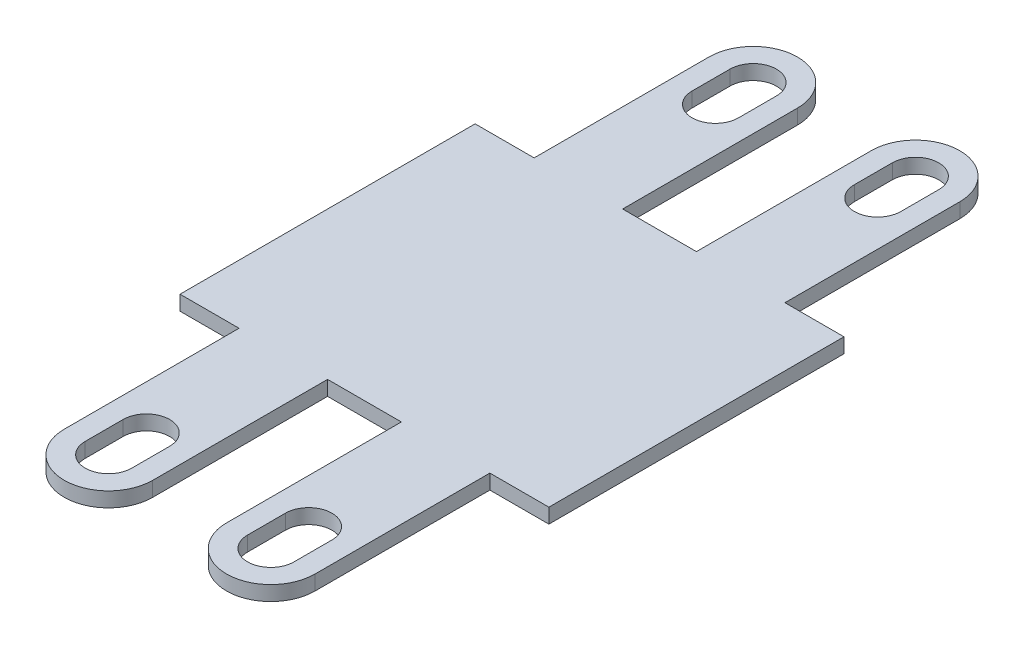
from build123d import *

# Parameters (mm, degrees)
BOSS_EXTRUDE1_DEPTH = 2


with BuildPart() as part:
    # Sketch1 → Boss-Extrude1 (new body)
    with BuildSketch(Plane(origin=(0, 0, 0), x_dir=(1, 0, 0), z_dir=(0, 1, 0))):
        with BuildLine():
            Line((-23.335340856, 23.970044555), (-15.335340856, 23.970044555))
            Line((-15.335340856, 23.970044555), (-15.335340856, 47.670044555))
            ThreePointArc((-15.335340856, 47.670044555), (-9.335340856, 53.670044555), (-3.335340856, 47.670044555))
            Line((-3.335340856, 47.670044555), (-3.335340856, 23.970044555))
            Line((-3.335340856, 23.970044555), (6.664659144, 23.970044555))
            Line((6.664659144, 23.970044555), (6.664659144, 47.670044555))
            ThreePointArc((6.664659144, 47.670044555), (12.664659144, 53.670044555), (18.664659144, 47.670044555))
            Line((18.664659144, 47.670044555), (18.664659144, 23.970044555))
            Line((18.664659144, 23.970044555), (26.664659144, 23.970044555))
            Line((26.664659144, 23.970044555), (26.664659144, -16.029955445))
            Line((26.664659144, -16.029955445), (18.664659144, -16.029955445))
            Line((18.664659144, -16.029955445), (18.664659144, -39.729955445))
            ThreePointArc((18.664659144, -39.729955445), (12.664659144, -45.729955445), (6.664659144, -39.729955445))
            Line((6.664659144, -39.729955445), (6.664659144, -16.029955445))
            Line((6.664659144, -16.029955445), (-3.335340856, -16.029955445))
            Line((-3.335340856, -16.029955445), (-3.335340856, -39.729955445))
            ThreePointArc((-3.335340856, -39.729955445), (-9.335340856, -45.729955445), (-15.335340856, -39.729955445))
            Line((-15.335340856, -39.729955445), (-15.335340856, -16.029955445))
            Line((-15.335340856, -16.029955445), (-23.335340856, -16.029955445))
            Line((-23.335340856, -16.029955445), (-23.335340856, 23.970044555))
        make_face()
        with BuildLine():
            Line((9.514659144, 47.670044555), (9.514659144, 42.529492266))
            ThreePointArc((9.514659144, 42.529492266), (12.664659144, 39.379492266), (15.814659144, 42.529492266))
            Line((15.814659144, 42.529492266), (15.814659144, 47.670044555))
            ThreePointArc((15.814659144, 47.670044555), (12.664659144, 50.820044555), (9.514659144, 47.670044555))
        make_face(mode=Mode.SUBTRACT)
        with BuildLine():
            Line((-6.185340856, 47.670044555), (-6.185340856, 42.529492266))
            ThreePointArc((-6.185340856, 42.529492266), (-9.335340856, 39.379492266), (-12.485340856, 42.529492266))
            Line((-12.485340856, 42.529492266), (-12.485340856, 47.670044555))
            ThreePointArc((-12.485340856, 47.670044555), (-9.335340856, 50.820044555), (-6.185340856, 47.670044555))
        make_face(mode=Mode.SUBTRACT)
        with BuildLine():
            Line((9.514659144, -39.729955445), (9.514659144, -34.589403157))
            ThreePointArc((9.514659144, -34.589403157), (12.664659144, -31.439403157), (15.814659144, -34.589403157))
            Line((15.814659144, -34.589403157), (15.814659144, -39.729955445))
            ThreePointArc((15.814659144, -39.729955445), (12.664659144, -42.879955445), (9.514659144, -39.729955445))
        make_face(mode=Mode.SUBTRACT)
        with BuildLine():
            Line((-6.185340856, -39.729955445), (-6.185340856, -34.589403157))
            ThreePointArc((-6.185340856, -34.589403157), (-9.335340856, -31.439403157), (-12.485340856, -34.589403157))
            Line((-12.485340856, -34.589403157), (-12.485340856, -39.729955445))
            ThreePointArc((-12.485340856, -39.729955445), (-9.335340856, -42.879955445), (-6.185340856, -39.729955445))
        make_face(mode=Mode.SUBTRACT)
    extrude(amount=BOSS_EXTRUDE1_DEPTH)


solid = part.part
